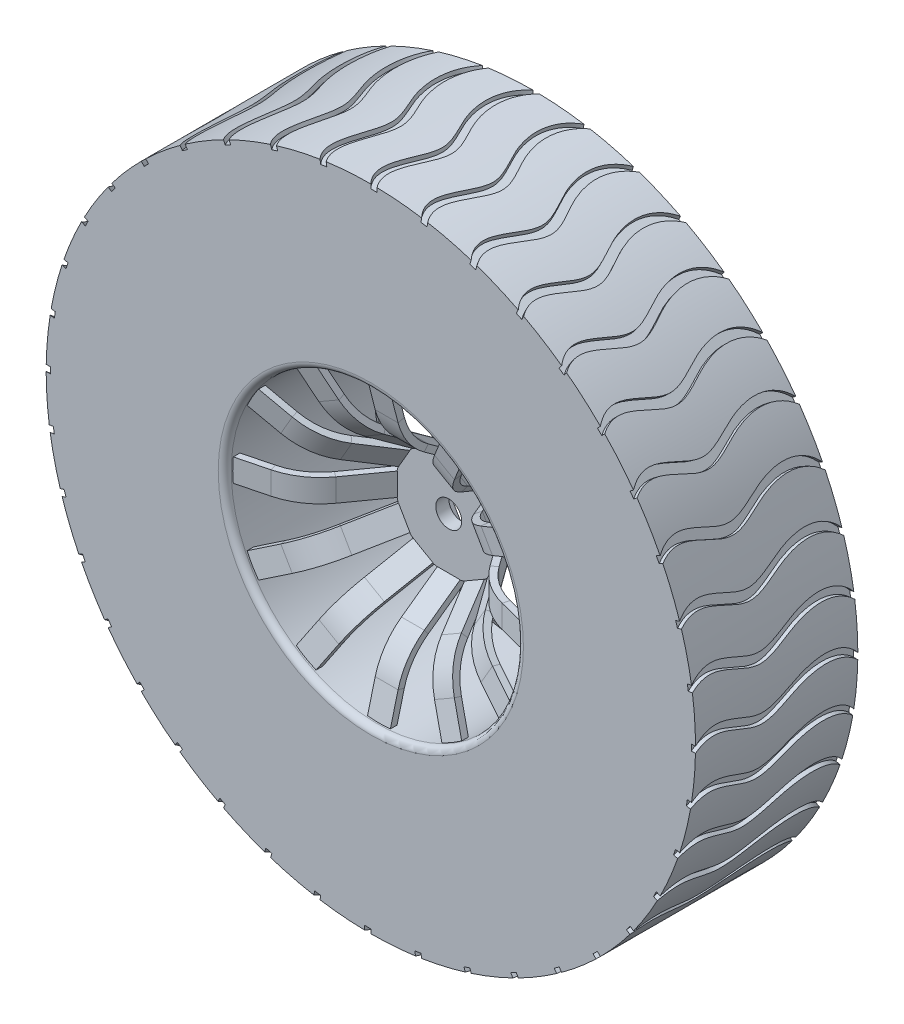
from build123d import *

# Parameters (mm, degrees)
SKETCH_1_R               = 8.15
EXTRUDE_1_DEPTH          = 6
SKETCH_2_R               = 2
CUT_EXTRUDE_1_DEPTH      = 6
CUT_EXTRUDE_2_DEPTH      = 4
SKETCH_4_R               = 50
SKETCH_4_R_2             = 22.5
EXTRUDE_2_DEPTH          = 25
SKETCH_5_W               = 1
SKETCH_5_H               = 3.52
PATTERN_CIRCULAR_1_COUNT = 12
SKETCH_7_R               = 2
CUT_EXTRUDE_3_DEPTH      = 25
FILLET_1_R               = 1
CHAMFER_1_SIZE           = 2
SKETCH_8_R               = 32.5
SKETCH_8_R_2             = 26
EXTRUDE_3_DEPTH          = 25
CUT_EXTRUDE_START        = 19
CUT_EXTRUDE_4_DEPTH      = 3
PATTERN_CIRCULAR_2_COUNT = 40


with BuildPart() as part:
    # Эскиз1 → Бобышка-Вытянуть1 (new body)
    with BuildSketch(Plane.XY):
        Circle(SKETCH_1_R)
    extrude(amount=EXTRUDE_1_DEPTH)

    # Эскиз2 → Вырез-Вытянуть1 (cut)
    with BuildSketch(Plane.XY.offset(6)):
        Circle(SKETCH_2_R)
    extrude(amount=-CUT_EXTRUDE_1_DEPTH, mode=Mode.SUBTRACT)

    # Эскиз3 → Вырез-Вытянуть2 (cut)
    with BuildSketch(Plane(origin=(0, 0, 0), x_dir=(-1, 0, 0), z_dir=(0, 0, -1))):
        Polygon((-7.67875858, 0), (-3.83937929, -6.65), (3.83937929, -6.65), (7.67875858, 0), (3.83937929, 6.65), (-3.83937929, 6.65), align=None)
    extrude(amount=-CUT_EXTRUDE_2_DEPTH, mode=Mode.SUBTRACT)



with BuildPart() as body_2:
    # Эскиз4 → Бобышка-Вытянуть2 (new body)
    with BuildSketch(Plane.XY.offset(18)):
        Circle(SKETCH_4_R)
        Circle(SKETCH_4_R_2, mode=Mode.SUBTRACT)
    extrude(amount=-EXTRUDE_2_DEPTH)


with BuildPart() as part_1:
    add(part.part)

    add(body_2.part)  # По траектории2 merges body 2
    # По траектории2: sweep along a path in Эскиз6
    with BuildLine(Plane(origin=(0, 0, 0), x_dir=(1, 0, 0), z_dir=(0, 1, 0))) as sweep_2_path:
        Line((-23.253816851, -16.444333242), (-17.924891552, -15.081119793))
        ThreePointArc((-17.924891552, -15.081119793), (-14.763503904, -13.651031756), (-12.281111697, -11.226727198))
        Line((-12.281111697, -11.226727198), (-8.167941181, -5.5))
        Line((-8.167941181, -5.5), (-2.021843686, -5.5))
        Line((-2.021843686, -5.5), (0, -5.5))
    # Эскиз5 → По траектории2 (sweep)
    with BuildSketch(Plane(origin=(0, 0, 0), x_dir=(0, 0, -1), z_dir=(1, 0, 0))):
        with Locations((-5.5, 0)):
            Rectangle(SKETCH_5_W, SKETCH_5_H)
    sweep_2 = sweep(path=sweep_2_path.line, transition=Transition.RIGHT)

    # Круговой массив1: По траектории2 ×12 about axis
    pattern_circular_1_axis = Axis((0, 0, 0), (0, 0, 1))
    for i in range(1, PATTERN_CIRCULAR_1_COUNT):
        add(sweep_2.rotate(pattern_circular_1_axis, i * 360 / PATTERN_CIRCULAR_1_COUNT))

    # Эскиз7 → Вырез-Вытянуть3 (cut)
    with BuildSketch(Plane(origin=(0, 0, 5), x_dir=(-1, 0, 0), z_dir=(0, 0, -1))):
        Circle(SKETCH_7_R)
    extrude(amount=-CUT_EXTRUDE_3_DEPTH, mode=Mode.SUBTRACT)

    # Скругление1
    fillet_1_edges = [part_1.edges().sort_by_distance(p)[0] for p in [
        (-22.5, 0, 18),
    ]]
    fillet(fillet_1_edges, radius=FILLET_1_R)

    # Фаска1
    chamfer_1_edges = [part_1.edges().sort_by_distance(p)[0] for p in [
        (-22.5, 0, -7),
    ]]
    chamfer(chamfer_1_edges, length=CHAMFER_1_SIZE)

    # Эскиз8 → Бобышка-Вытянуть3 (add)
    with BuildSketch(Plane(origin=(0, 0, -7), x_dir=(-1, 0, 0), z_dir=(0, 0, -1))):
        Circle(SKETCH_8_R)
        Circle(SKETCH_8_R_2, mode=Mode.SUBTRACT)
    extrude(amount=-EXTRUDE_3_DEPTH)

    # Эскиз9 → Вырез-Вытянуть4 (cut)
    with BuildSketch(Plane(origin=(0, 33.35, 0), x_dir=(1, 0, 0), z_dir=(0, 1, 0)).offset(CUT_EXTRUDE_START)):
        with BuildLine():
            Line((0, 7), (0.948977047, 7))
            add(Edge.make_bspline(
                [(0.948977047, 7), (-1.48480512, 4.456729271), (-1.272811936, -1.145571253), (4.429796697, -8.951867156), (-1.80543664, -14.394601901), (0.948977047, -18)],
                knots=[0, 0, 0, 0, 0.368015909, 0.592617887, 1, 1, 1, 1], degree=3))
            Line((0.948977047, -18), (0, -18))
            add(Edge.make_bspline(
                [(0, 7), (-2.914386455, 4.666347352), (-2.68277247, -1.080336757), (2.889703668, -8.983590474), (-3.391932092, -14.445493006), (0, -18)],
                knots=[0, 0, 0, 0, 0.372359004, 0.594016028, 1, 1, 1, 1], degree=3))
        make_face()
    cut_extrude_4 = extrude(amount=-CUT_EXTRUDE_4_DEPTH, mode=Mode.SUBTRACT)

    # Круговой массив2: Вырез-Вытянуть4 ×40 about axis
    pattern_circular_2_axis = Axis((0, 0, 0), (0, 0, 1))
    for i in range(1, PATTERN_CIRCULAR_2_COUNT):
        add(cut_extrude_4.rotate(pattern_circular_2_axis, i * 360 / PATTERN_CIRCULAR_2_COUNT), mode=Mode.SUBTRACT)


solid = part_1.part
